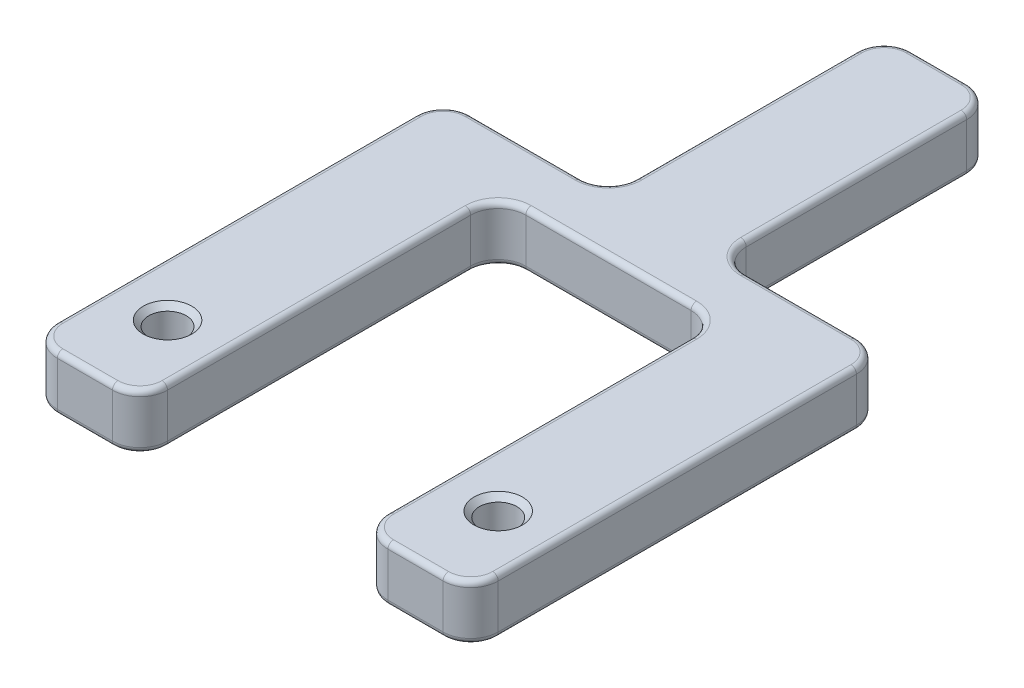
from build123d import *

# Parameters (mm, degrees)
BOSS_EXTRUDE1_DEPTH      = 5
M3_CLEARANCE_HOLE1_D     = 3.4
M3_CLEARANCE_HOLE1_DEPTH = 5
M3_CLEARANCE_HOLE1_TIP   = 1.021463052
FILLET1_R                = 2.5
CHAMFER1_SIZE            = 0.5
FILLET2_R                = 0.5


with BuildPart() as part:
    # Sketch3 → Boss-Extrude1 (new body)
    with BuildSketch(Plane(origin=(0, 0, 0), x_dir=(1, 0, 0), z_dir=(0, 1, 0))):
        Polygon((0, 55), (0, 25), (-10, 25), (-10, -7.5), (-20, -7.5), (-20, 30), (-5, 30), (-5, 55), align=None)
    boss_extrude1 = extrude(amount=BOSS_EXTRUDE1_DEPTH)

    # Mirror1: Boss-Extrude1 across plane
    add(boss_extrude1.mirror(Plane(origin=(0, 0, 0), x_dir=(0, 0, 1), z_dir=(1, 0, 0))))

    # M3 Clearance Hole1
    with Locations(Plane(origin=(0, 5, 0), x_dir=(1, 0, 0), z_dir=(0, 1, 0))):
        with Locations((-15, 0), (15, 0)):
            Hole(M3_CLEARANCE_HOLE1_D / 2, depth=M3_CLEARANCE_HOLE1_DEPTH)
            with Locations((0, 0, -(M3_CLEARANCE_HOLE1_DEPTH + M3_CLEARANCE_HOLE1_TIP / 2))):  # 118° drill point
                Cone(0, M3_CLEARANCE_HOLE1_D / 2, M3_CLEARANCE_HOLE1_TIP, mode=Mode.SUBTRACT)

    # Fillet1
    fillet1_edges = [part.edges().sort_by_distance(p)[0] for p in [
        (-10, 2.5, -25),
        (-10, 2.5, 7.5),
        (-20, 2.5, 7.5),
        (-20, 2.5, -30),
        (-5, 2.5, -30),
        (-5, 2.5, -55),
        (5, 2.5, -55),
        (10, 2.5, -25),
        (10, 2.5, 7.5),
        (20, 2.5, 7.5),
        (20, 2.5, -30),
        (5, 2.5, -30),
    ]]
    fillet(fillet1_edges, radius=FILLET1_R)

    # Chamfer1
    chamfer1_edges = [part.edges().sort_by_distance(p)[0] for p in [
        (16.7, 5, 0),
        (16.7, 0, 0),
        (-13.3, 5, 0),
        (-13.3, 0, 0),
    ]]
    chamfer(chamfer1_edges, length=CHAMFER1_SIZE)

    # Fillet2
    fillet2_edges = [part.edges().sort_by_distance(p)[0] for p in [
        (5.732233047, 0, -30.732233047),
        (5.732233047, 5, -30.732233047),
        (9.267766953, 0, -24.267766953),
        (9.267766953, 5, -24.267766953),
        (-9.267766953, 0, -24.267766953),
        (-9.267766953, 5, -24.267766953),
        (-12.5, 0, -30),
        (-12.5, 5, -30),
        (-5, 0, -42.5),
        (-5, 5, -42.5),
        (-20, 0, -11.25),
        (-20, 5, -11.25),
        (0, 0, -55),
        (5, 0, -42.5),
        (12.5, 0, -30),
        (20, 0, -11.25),
        (15, 0, 7.5),
        (10, 0, -8.75),
        (0, 0, -25),
        (-10, 0, -8.75),
        (-15, 0, 7.5),
        (-19.267766953, 0, 6.767766953),
        (-10.732233047, 0, 6.767766953),
        (10.732233047, 0, 6.767766953),
        (19.267766953, 0, 6.767766953),
        (19.267766953, 0, -29.267766953),
        (4.267766953, 0, -54.267766953),
        (-4.267766953, 0, -54.267766953),
        (-19.267766953, 0, -29.267766953),
        (0, 5, -55),
        (-15, 5, 7.5),
        (-10, 5, -8.75),
        (0, 5, -25),
        (10, 5, -8.75),
        (15, 5, 7.5),
        (20, 5, -11.25),
        (12.5, 5, -30),
        (5, 5, -42.5),
        (-19.267766953, 5, 6.767766953),
        (-10.732233047, 5, 6.767766953),
        (10.732233047, 5, 6.767766953),
        (19.267766953, 5, 6.767766953),
        (19.267766953, 5, -29.267766953),
        (4.267766953, 5, -54.267766953),
        (-4.267766953, 5, -54.267766953),
        (-19.267766953, 5, -29.267766953),
        (-5.732233047, 0, -30.732233047),
        (-5.732233047, 5, -30.732233047),
    ]]
    fillet(fillet2_edges, radius=FILLET2_R)


solid = part.part
